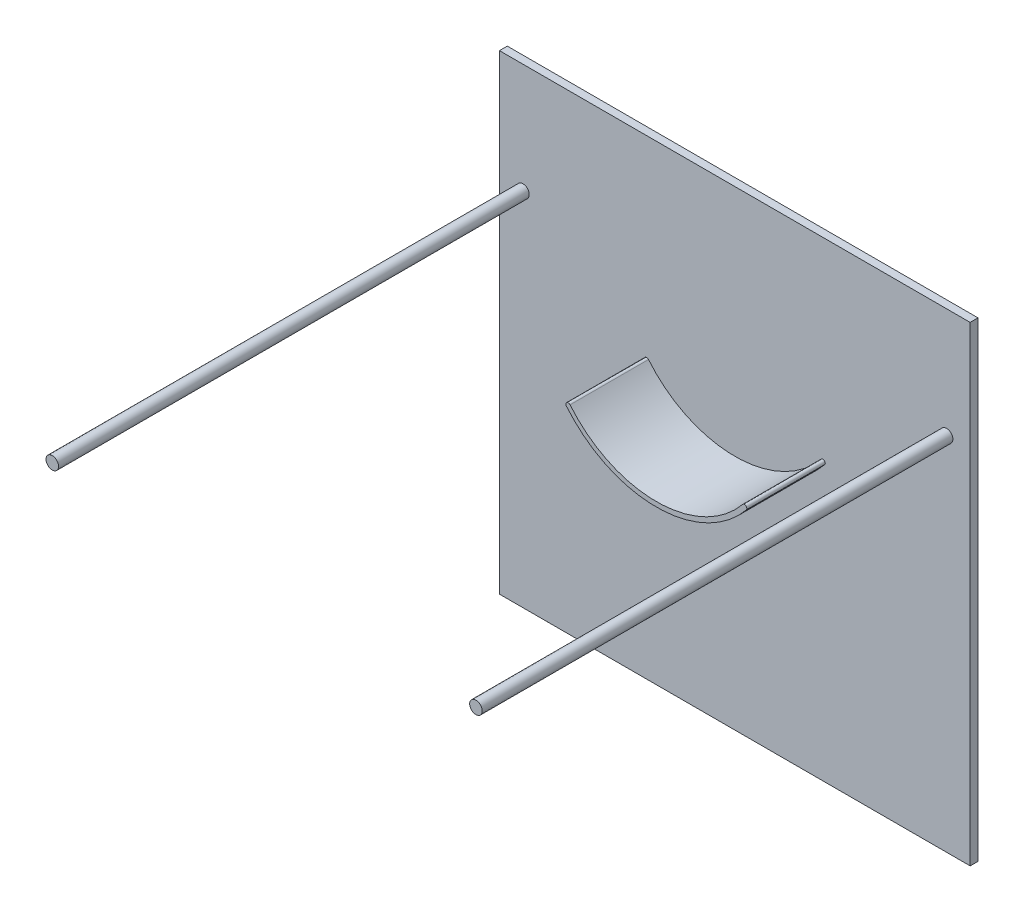
from build123d import *

# Parameters (mm, degrees)
ESQUISSE1_W        = 300
ESQUISSE1_H        = 300
BOSS_EXTRU_1_DEPTH = 5
ESQUISSE2_R        = 4
BOSS_EXTRU_2_DEPTH = 300
BOSS_EXTRU_4_DEPTH = 50


with BuildPart() as part:
    # Esquisse1 → Boss.-Extru.1 (new body)
    with BuildSketch(Plane.XY):
        with Locations((150, -150)):
            Rectangle(ESQUISSE1_W, ESQUISSE1_H)
    extrude(amount=BOSS_EXTRU_1_DEPTH)

    # Esquisse2 → Boss.-Extru.2 (add)
    with BuildSketch(Plane.XY.offset(5)):
        with Locations((15, -70)):
            Circle(ESQUISSE2_R)
        with Locations((285, -70)):
            Circle(ESQUISSE2_R)
    extrude(amount=BOSS_EXTRU_2_DEPTH)

    # Esquisse5 → Boss.-Extru.4 (add)
    with BuildSketch(Plane.XY.offset(5)):
        with BuildLine():
            ThreePointArc((95, -122.991547009), (150, -148.920572223), (205, -122.991547009))
            ThreePointArc((205, -122.991547009), (207.11161857, -122.788897028), (207.314268551, -124.900515598))
            ThreePointArc((207.314268551, -124.900515598), (150, -151.920572223), (92.685731449, -124.900515598))
            ThreePointArc((92.685731449, -124.900515598), (92.88838143, -122.788897028), (95, -122.991547009))
        make_face()
    extrude(amount=BOSS_EXTRU_4_DEPTH)


solid = part.part
